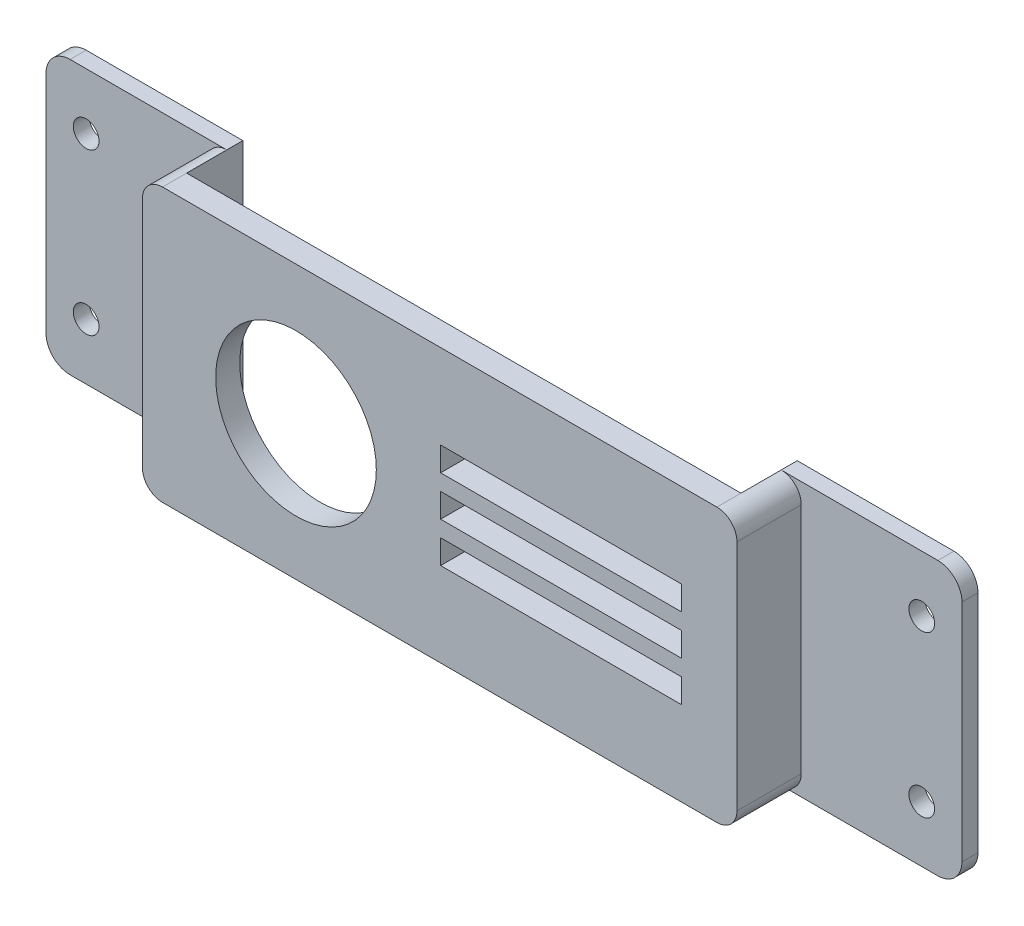
from build123d import *

# Parameters (mm, degrees)
SKETCH1_R           = 10
SKETCH1_W           = 30
SKETCH1_H           = 3
BOSS_EXTRUDE1_DEPTH = 3
BOSS_EXTRUDE3_DEPTH = 5
SKETCH2_W           = 22.5
SKETCH2_H           = 34
BOSS_EXTRUDE2_DEPTH = 2
SKETCH4_R           = 1.6
CUT_EXTRUDE1_DEPTH  = 11
FILLET1_R           = 3


with BuildPart() as part:
    # Sketch1 → Boss-Extrude1 (new body)
    with BuildSketch(Plane.XY):
        with BuildLine():
            Line((-150, 98.203720637), (-150, 69.203720637))
            ThreePointArc((-150, 69.203720637), (-149.267766953, 67.435953684), (-147.5, 66.703720637))
            Line((-147.5, 66.703720637), (-78.5, 66.703720637))
            ThreePointArc((-78.5, 66.703720637), (-76.732233047, 67.435953684), (-76, 69.203720637))
            Line((-76, 69.203720637), (-76, 98.203720637))
            ThreePointArc((-76, 98.203720637), (-76.732233047, 99.97148759), (-78.5, 100.703720637))
            Line((-78.5, 100.703720637), (-147.5, 100.703720637))
            ThreePointArc((-147.5, 100.703720637), (-149.267766953, 99.97148759), (-150, 98.203720637))
        make_face()
        with Locations((-130.886316496, 83.527802162)):
            Circle(SKETCH1_R, mode=Mode.SUBTRACT)
        with Locations((-97.886316496, 83.703720637)):
            Rectangle(SKETCH1_W, SKETCH1_H, mode=Mode.SUBTRACT)
        with Locations((-97.886316496, 88.703720637)):
            Rectangle(SKETCH1_W, SKETCH1_H, mode=Mode.SUBTRACT)
        with Locations((-97.886316496, 78.703720637)):
            Rectangle(SKETCH1_W, SKETCH1_H, mode=Mode.SUBTRACT)
    extrude(amount=-BOSS_EXTRUDE1_DEPTH)

    # Sketch3 → Boss-Extrude3 (add)
    with BuildSketch(Plane(origin=(0, 0, -3), x_dir=(-1, 0, 0), z_dir=(0, 0, -1))):
        with BuildLine():
            Line((150, 98.203720637), (150, 69.203720637))
            ThreePointArc((150, 69.203720637), (149.267766953, 67.435953684), (147.5, 66.703720637))
            Line((147.5, 66.703720637), (147.5, 100.703720637))
            ThreePointArc((147.5, 100.703720637), (149.267766953, 99.97148759), (150, 98.203720637))
        make_face()
        with BuildLine():
            Line((78.5, 100.703720637), (78.5, 66.703720637))
            ThreePointArc((78.5, 66.703720637), (76.732233047, 67.435953684), (76, 69.203720637))
            Line((76, 69.203720637), (76, 98.203720637))
            ThreePointArc((76, 98.203720637), (76.732233047, 99.97148759), (78.5, 100.703720637))
        make_face()
    extrude(amount=BOSS_EXTRUDE3_DEPTH)

    # Sketch2 → Boss-Extrude2 (add)
    with BuildSketch(Plane(origin=(0, 0, -8), x_dir=(-1, 0, 0), z_dir=(0, 0, -1))):
        with Locations((158.75, 83.703720637)):
            Rectangle(SKETCH2_W, SKETCH2_H)
        with Locations((67.25, 83.703720637)):
            Rectangle(SKETCH2_W, SKETCH2_H)
    extrude(amount=BOSS_EXTRUDE2_DEPTH)

    # Sketch4 → Cut-Extrude1 (cut, through all)
    with BuildSketch(Plane(origin=(0, 0, -10), x_dir=(-1, 0, 0), z_dir=(0, 0, -1))):
        with Locations((61, 93.703720637)):
            Circle(SKETCH4_R)
        with Locations((61, 73.703720637)):
            Circle(SKETCH4_R)
        with Locations((165, 73.703720637)):
            Circle(SKETCH4_R)
        with Locations((165, 93.703720637)):
            Circle(SKETCH4_R)
    extrude(amount=-CUT_EXTRUDE1_DEPTH, mode=Mode.SUBTRACT)

    # Fillet1
    fillet1_edges = [part.edges().sort_by_distance(p)[0] for p in [
        (-56, 100.703720637, -9),
        (-56, 66.703720637, -9),
        (-170, 66.703720637, -9),
        (-170, 100.703720637, -9),
    ]]
    fillet(fillet1_edges, radius=FILLET1_R)


solid = part.part
